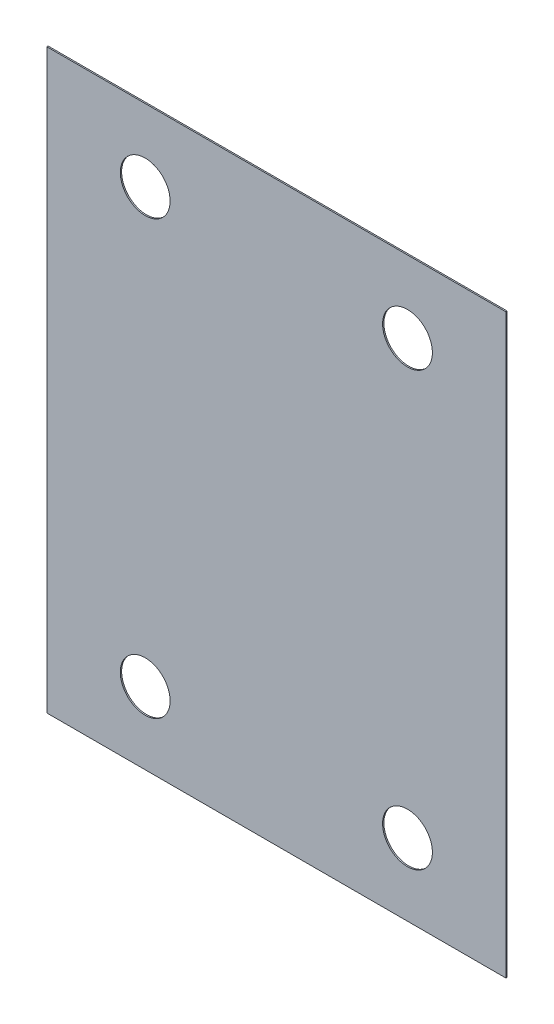
from build123d import *

# Parameters (mm, degrees)
SKETCH_1_W      = 350
SKETCH_1_H      = 440
SKETCH_1_R      = 19
EXTRUDE_1_DEPTH = 1


with BuildPart() as part:
    # Эскиз1 → Бобышка-Вытянуть1 (new body)
    with BuildSketch(Plane.XY):
        Rectangle(SKETCH_1_W, SKETCH_1_H)
        with Locations((-100, 165)):
            Circle(SKETCH_1_R, mode=Mode.SUBTRACT)
        with Locations((100, 165)):
            Circle(SKETCH_1_R, mode=Mode.SUBTRACT)
        with Locations((100, -165)):
            Circle(SKETCH_1_R, mode=Mode.SUBTRACT)
        with Locations((-100, -165)):
            Circle(SKETCH_1_R, mode=Mode.SUBTRACT)
    extrude(amount=EXTRUDE_1_DEPTH)


solid = part.part
